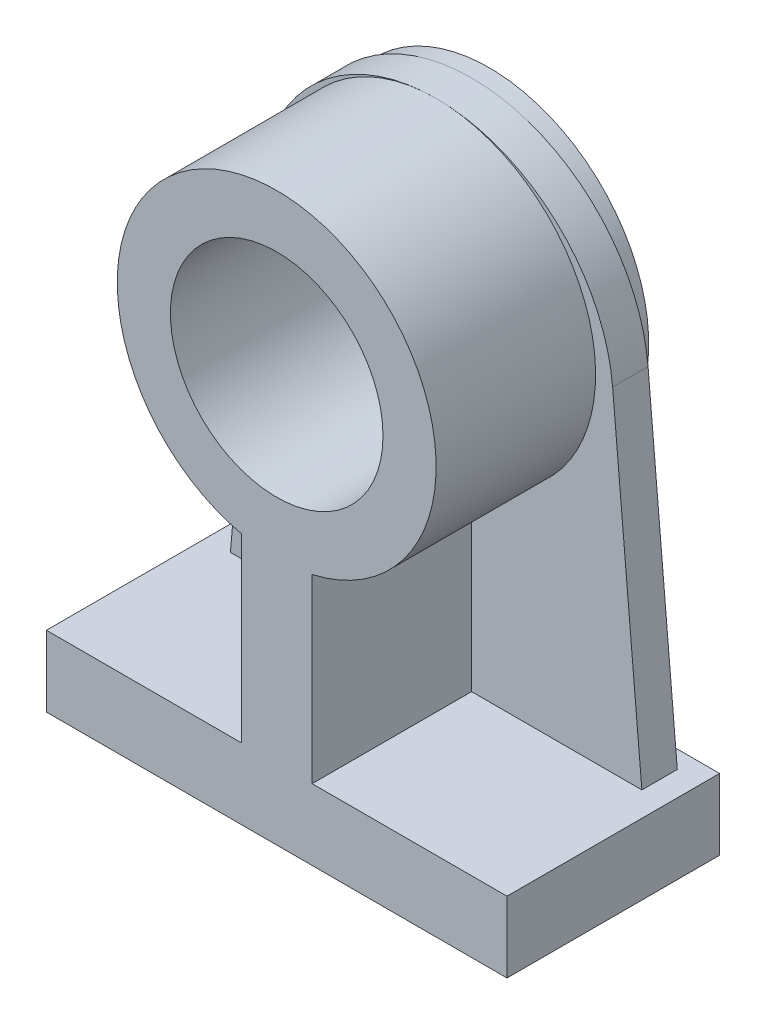
from build123d import *

# Parameters (mm, degrees)
SKICA1_R                     = 15
P_IDAT_VYSUNUT_M1_DEPTH      = 2.5
P_IDAT_VYSUNUT_M2_DEPTH      = 25
P_IDAT_VYSUNUT_M2_DEPTH_BACK = 5
SKICA1_3_R                   = 15


with BuildPart() as part:
    # Skica1 → P_idat vysunut_m1 (new, symmetric)
    with BuildSketch(Plane.XY):
        with BuildLine():
            Line((32.5, 5), (29.032485797, 5))
            Line((29.032485797, 5), (24.904867452, 52.178893569))
            ThreePointArc((24.904867452, 52.178893569), (0, 75), (-24.904867452, 52.178893569))
            Line((-24.904867452, 52.178893569), (-29.032485797, 5))
            Line((-29.032485797, 5), (-32.5, 5))
            Line((-32.5, 5), (-32.5, -5))
            Line((-32.5, -5), (32.5, -5))
            Line((32.5, -5), (32.5, 5))
        make_face()
        with Locations((0, 52.5)):
            Circle(SKICA1_R, mode=Mode.SUBTRACT)
    extrude(amount=P_IDAT_VYSUNUT_M1_DEPTH, both=True)

    # Skica1_3 → P_idat vysunut_m2 (add, two sides: drawn at the far end of the back side and taken through both)
    with BuildSketch(Plane.XY.offset(-P_IDAT_VYSUNUT_M2_DEPTH_BACK)):
        with BuildLine():
            ThreePointArc((-7.9e-08, 75), (-22.358910385, 55.015775508), (-5, 30.562589032))
            Line((-5, 30.562589032), (-5, 5))
            Line((-5, 5), (-29.032485797, 5))
            Line((-29.032485797, 5), (-32.5, 5))
            Line((-32.5, 5), (-32.5, -5))
            Line((-32.5, -5), (32.5, -5))
            Line((32.5, -5), (32.5, 5))
            Line((32.5, 5), (29.032485797, 5))
            Line((29.032485797, 5), (5, 5))
            Line((5, 5), (5, 30.562589032))
            ThreePointArc((5, 30.562589032), (22.358910376, 55.015775587), (-7.9e-08, 75))
        make_face()
        with Locations((0, 52.5)):
            Circle(SKICA1_3_R, mode=Mode.SUBTRACT)
    extrude(amount=P_IDAT_VYSUNUT_M2_DEPTH + P_IDAT_VYSUNUT_M2_DEPTH_BACK)


solid = part.part
